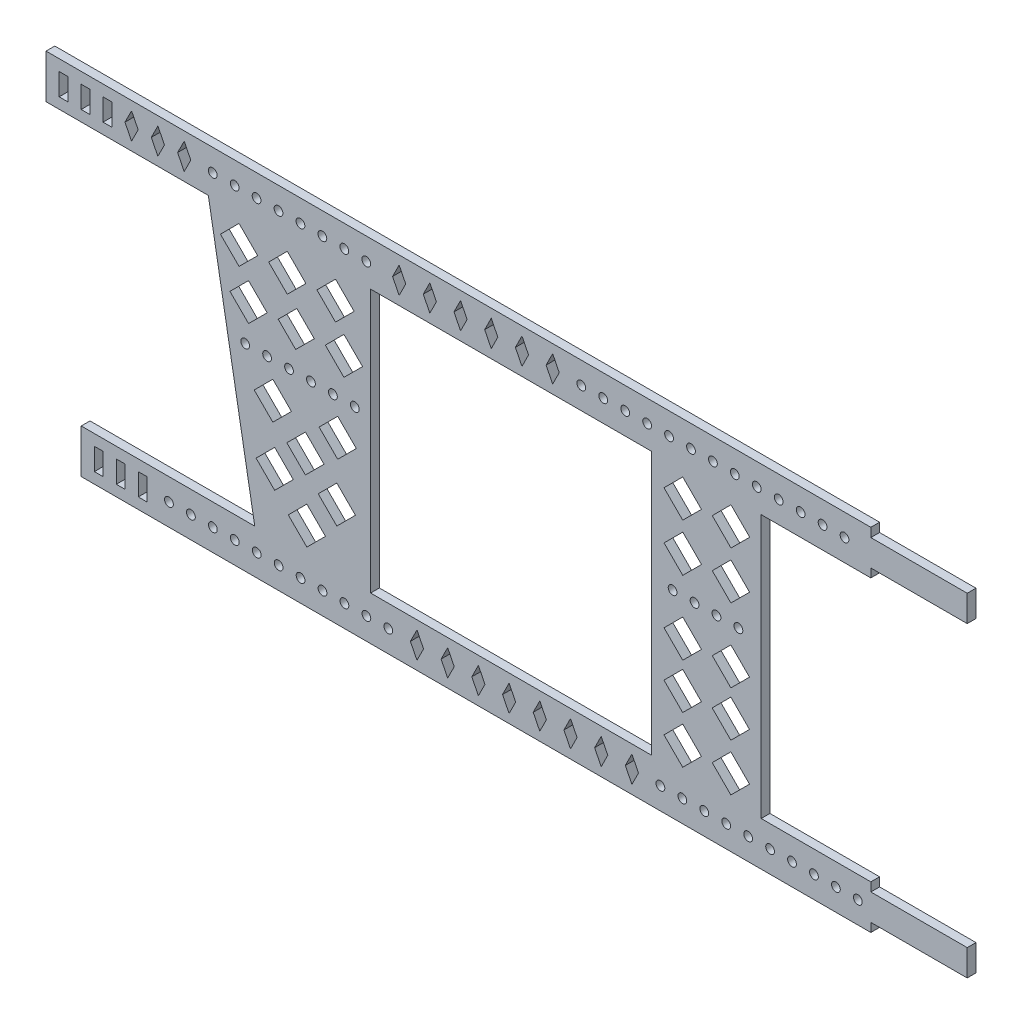
from build123d import *

# Parameters (mm, degrees)
SKETCH_1_W      = 2
SKETCH_1_H      = 5
SKETCH_1_R      = 1
SKETCH_1_W_2    = 64.030489503
SKETCH_1_H_2    = 60
EXTRUDE_1_DEPTH = 2


with BuildPart() as part:
    # 草图1 → 凸台-拉伸1 (new body)
    with BuildSketch(Plane.XY):
        Polygon((88.030596148, 5.035282886), (-99.999893355, 5.035282886), (-99.999893355, -4.964717114), (-62.999893355, -4.964717114), (-52.420274512, -64.964717114), (-91.969403852, -64.964717114), (-91.969403852, -74.964717114), (88.030596148, -74.964717114), (88.030596148, -72.964717114), (110.000106645, -72.964717114), (110.000106645, -66.964717114), (88.030596148, -66.964717114), (88.030596148, -64.964717114), (63.030596148, -64.964717114), (63.030596148, -4.964717114), (88.030596148, -4.964717114), (88.030596148, -2.99999245), (110.000106645, -2.99999245), (110.000106645, 3.00000755), (88.030596148, 3.00000755), align=None)
        with Locations((-87.969403852, -69.977475528)):
            Rectangle(SKETCH_1_W, SKETCH_1_H, mode=Mode.SUBTRACT)
        with Locations((-82.969403852, -69.977475528)):
            Rectangle(SKETCH_1_W, SKETCH_1_H, mode=Mode.SUBTRACT)
        with Locations((-77.969403852, -69.977475528)):
            Rectangle(SKETCH_1_W, SKETCH_1_H, mode=Mode.SUBTRACT)
        with Locations((-71.969403852, -69.964717114)):
            Circle(SKETCH_1_R, mode=Mode.SUBTRACT)
        with Locations((-66.969403852, -69.964717114)):
            Circle(SKETCH_1_R, mode=Mode.SUBTRACT)
        with Locations((-61.969403852, -69.964717114)):
            Circle(SKETCH_1_R, mode=Mode.SUBTRACT)
        with Locations((-56.969403852, -69.964717114)):
            Circle(SKETCH_1_R, mode=Mode.SUBTRACT)
        with Locations((-51.969403852, -69.964717114)):
            Circle(SKETCH_1_R, mode=Mode.SUBTRACT)
        with Locations((-46.969403852, -69.964717114)):
            Circle(SKETCH_1_R, mode=Mode.SUBTRACT)
        with Locations((-41.969403852, -69.964717114)):
            Circle(SKETCH_1_R, mode=Mode.SUBTRACT)
        with Locations((-36.969403852, -69.964717114)):
            Circle(SKETCH_1_R, mode=Mode.SUBTRACT)
        with Locations((-31.969403852, -69.964717114)):
            Circle(SKETCH_1_R, mode=Mode.SUBTRACT)
        with Locations((-26.969403852, -69.964717114)):
            Circle(SKETCH_1_R, mode=Mode.SUBTRACT)
        with Locations((-21.969403852, -69.964717114)):
            Circle(SKETCH_1_R, mode=Mode.SUBTRACT)
        Polygon((-15.435372884, -66.966180231), (-13.935372884, -69.966187781), (-15.435372884, -72.966195331), (-16.935372884, -69.966187781), align=None, mode=Mode.SUBTRACT)
        Polygon((-8.435372884, -72.966195331), (-9.935372884, -69.966187781), (-8.435372884, -66.966180231), (-6.935372884, -69.966187781), align=None, mode=Mode.SUBTRACT)
        Polygon((-44.780702844, -58.918058275), (-40.538062157, -54.675417588), (-36.29542147, -58.918058275), (-40.538062157, -63.160698962), align=None, mode=Mode.SUBTRACT)
        Polygon((-52.114588356, -51.383697663), (-47.871947669, -47.141056976), (-43.629306982, -51.383697663), (-47.871947669, -55.62633835), align=None, mode=Mode.SUBTRACT)
        Polygon((-37.95128426, -51.345378073), (-33.708643573, -47.102737386), (-29.466002886, -51.345378073), (-33.708643573, -55.58801876), align=None, mode=Mode.SUBTRACT)
        Polygon((-45.106332508, -44.847494945), (-40.863691821, -40.604854258), (-36.621051134, -44.847494945), (-40.863691821, -49.090135632), align=None, mode=Mode.SUBTRACT)
        Polygon((-52.536676588, -38.141926095), (-48.294035901, -33.899285408), (-44.051395214, -38.141926095), (-48.294035901, -42.384566782), align=None, mode=Mode.SUBTRACT)
        Polygon((-37.748086888, -38.065793199), (-33.505446201, -33.823152512), (-29.262805514, -38.065793199), (-33.505446201, -42.308433886), align=None, mode=Mode.SUBTRACT)
        Polygon((-1.435372884, -72.966195331), (-2.935372884, -69.966187781), (-1.435372884, -66.966180231), (0.064627116, -69.966187781), align=None, mode=Mode.SUBTRACT)
        Polygon((5.564627116, -72.966195331), (4.064627116, -69.966187781), (5.564627116, -66.966180231), (7.064627116, -69.966187781), align=None, mode=Mode.SUBTRACT)
        Polygon((12.564627116, -72.966195331), (11.064627116, -69.966187781), (12.564627116, -66.966180231), (14.064627116, -69.966187781), align=None, mode=Mode.SUBTRACT)
        Polygon((19.564627116, -72.966195331), (18.064627116, -69.966187781), (19.564627116, -66.966180231), (21.064627116, -69.966187781), align=None, mode=Mode.SUBTRACT)
        Polygon((26.564627116, -72.966195331), (25.064627116, -69.966187781), (26.564627116, -66.966180231), (28.064627116, -69.966187781), align=None, mode=Mode.SUBTRACT)
        Polygon((33.564627116, -72.966195331), (32.064627116, -69.966187781), (33.564627116, -66.966180231), (35.064627116, -69.966187781), align=None, mode=Mode.SUBTRACT)
        with Locations((40.064627116, -69.964717114)):
            Circle(SKETCH_1_R, mode=Mode.SUBTRACT)
        with Locations((45.064627116, -69.964717114)):
            Circle(SKETCH_1_R, mode=Mode.SUBTRACT)
        with Locations((50.064627116, -69.964717114)):
            Circle(SKETCH_1_R, mode=Mode.SUBTRACT)
        with Locations((55.064627116, -69.964717114)):
            Circle(SKETCH_1_R, mode=Mode.SUBTRACT)
        with Locations((60.064627116, -69.964717114)):
            Circle(SKETCH_1_R, mode=Mode.SUBTRACT)
        with Locations((65.064627116, -69.964717114)):
            Circle(SKETCH_1_R, mode=Mode.SUBTRACT)
        with Locations((70.064627116, -69.964717114)):
            Circle(SKETCH_1_R, mode=Mode.SUBTRACT)
        with Locations((75.064627116, -69.964717114)):
            Circle(SKETCH_1_R, mode=Mode.SUBTRACT)
        with Locations((80.064627116, -69.964717114)):
            Circle(SKETCH_1_R, mode=Mode.SUBTRACT)
        with Locations((85.064627116, -69.964717114)):
            Circle(SKETCH_1_R, mode=Mode.SUBTRACT)
        Polygon((40.877840935, -59.522953409), (45.145983497, -55.254810846), (49.41412606, -59.522953409), (45.145983497, -63.791095971), align=None, mode=Mode.SUBTRACT)
        Polygon((51.865089997, -59.510202471), (56.120481622, -55.254810846), (60.375873246, -59.510202471), (56.120481622, -63.765594096), align=None, mode=Mode.SUBTRACT)
        with Locations((6.015351396, -34.964717114)):
            Rectangle(SKETCH_1_W_2, SKETCH_1_H_2, mode=Mode.SUBTRACT)
        Polygon((40.87382717, -48.72025407), (45.141969733, -44.452111507), (49.410112295, -48.72025407), (45.141969733, -52.988396632), align=None, mode=Mode.SUBTRACT)
        Polygon((51.861076232, -48.707503132), (56.116467857, -44.452111507), (60.371859482, -48.707503132), (56.116467857, -52.962894757), align=None, mode=Mode.SUBTRACT)
        Polygon((40.887199733, -38.383165413), (45.155342296, -34.115022851), (49.423484858, -38.383165413), (45.155342296, -42.651307976), align=None, mode=Mode.SUBTRACT)
        Polygon((51.887199733, -38.383165413), (56.12984042, -34.140524726), (60.372481107, -38.383165413), (56.12984042, -42.6258061), align=None, mode=Mode.SUBTRACT)
        with Locations((-54.598317058, -29.99999245)):
            Circle(SKETCH_1_R, mode=Mode.SUBTRACT)
        Polygon((-58.070528094, -21.436133175), (-53.827887407, -17.193492488), (-49.58524672, -21.436133175), (-53.827887407, -25.678773862), align=None, mode=Mode.SUBTRACT)
        with Locations((-49.598317058, -29.99999245)):
            Circle(SKETCH_1_R, mode=Mode.SUBTRACT)
        with Locations((-44.598317058, -29.99999245)):
            Circle(SKETCH_1_R, mode=Mode.SUBTRACT)
        with Locations((-39.598317058, -29.99999245)):
            Circle(SKETCH_1_R, mode=Mode.SUBTRACT)
        with Locations((-34.598317058, -29.99999245)):
            Circle(SKETCH_1_R, mode=Mode.SUBTRACT)
        with Locations((-29.598317058, -29.99999245)):
            Circle(SKETCH_1_R, mode=Mode.SUBTRACT)
        Polygon((-47.070528094, -21.436133175), (-42.827887407, -17.193492488), (-38.839924125, -21.18145577), (-43.082564812, -25.424096457), align=None, mode=Mode.SUBTRACT)
        Polygon((-36.325205499, -21.18145577), (-32.082564812, -16.938815083), (-27.839924125, -21.18145577), (-32.082564812, -25.424096457), align=None, mode=Mode.SUBTRACT)
        Polygon((-60.241215598, -11.234867157), (-55.998574911, -6.99222647), (-51.755934224, -11.234867157), (-55.998574911, -15.477507844), align=None, mode=Mode.SUBTRACT)
        with Locations((-96.000048897, 8.067e-06)):
            Rectangle(SKETCH_1_W, SKETCH_1_H, mode=Mode.SUBTRACT)
        with Locations((-91.000048897, 8.067e-06)):
            Rectangle(SKETCH_1_W, SKETCH_1_H, mode=Mode.SUBTRACT)
        with Locations((-86.000048897, 8.067e-06)):
            Rectangle(SKETCH_1_W, SKETCH_1_H, mode=Mode.SUBTRACT)
        Polygon((-80.499946677, -3.000106646), (-82.000048897, 0.000105344), (-80.499995574, 3.00021954), (-78.999893355, 7.55e-06), align=None, mode=Mode.SUBTRACT)
        Polygon((-74.499946677, -3.000106646), (-76.000048897, 0.000105344), (-74.499995574, 3.00021954), (-72.999893355, 7.55e-06), align=None, mode=Mode.SUBTRACT)
        Polygon((-68.499946677, -3.000106646), (-70.000048897, 0.000105344), (-68.499995574, 3.00021954), (-66.999893355, 7.55e-06), align=None, mode=Mode.SUBTRACT)
        with Locations((-61.999893355, 7.55e-06)):
            Circle(SKETCH_1_R, mode=Mode.SUBTRACT)
        with Locations((-56.999893355, 7.55e-06)):
            Circle(SKETCH_1_R, mode=Mode.SUBTRACT)
        with Locations((-51.999893355, 7.55e-06)):
            Circle(SKETCH_1_R, mode=Mode.SUBTRACT)
        Polygon((-49.241215598, -11.234867157), (-44.998574911, -6.99222647), (-40.755934224, -11.234867157), (-44.998574911, -15.477507844), align=None, mode=Mode.SUBTRACT)
        Polygon((-33.998574911, -6.99222647), (-29.755934224, -11.234867157), (-33.998574911, -15.477507844), (-38.241215598, -11.234867157), align=None, mode=Mode.SUBTRACT)
        with Locations((-46.999893355, 7.55e-06)):
            Circle(SKETCH_1_R, mode=Mode.SUBTRACT)
        with Locations((-41.999893355, 7.55e-06)):
            Circle(SKETCH_1_R, mode=Mode.SUBTRACT)
        with Locations((-36.999893355, 7.55e-06)):
            Circle(SKETCH_1_R, mode=Mode.SUBTRACT)
        with Locations((-31.999893355, 7.55e-06)):
            Circle(SKETCH_1_R, mode=Mode.SUBTRACT)
        with Locations((-26.999893355, 7.55e-06)):
            Circle(SKETCH_1_R, mode=Mode.SUBTRACT)
        Polygon((-19.499994314, -2.960033292), (-20.999994314, 0.039974259), (-19.499994314, 3.039981809), (-17.999994314, 0.039974259), align=None, mode=Mode.SUBTRACT)
        Polygon((-12.499994314, -2.960033292), (-13.999994314, 0.039974259), (-12.499994314, 3.039981809), (-10.999994314, 0.039974259), align=None, mode=Mode.SUBTRACT)
        Polygon((-5.499994314, -2.960033292), (-6.999994314, 0.039974259), (-5.499994314, 3.039981809), (-3.999994314, 0.039974259), align=None, mode=Mode.SUBTRACT)
        with Locations((42.844614024, -29.964205592)):
            Circle(SKETCH_1_R, mode=Mode.SUBTRACT)
        with Locations((47.844614024, -29.964205592)):
            Circle(SKETCH_1_R, mode=Mode.SUBTRACT)
        with Locations((52.844614024, -29.964205592)):
            Circle(SKETCH_1_R, mode=Mode.SUBTRACT)
        with Locations((57.844614024, -29.964205592)):
            Circle(SKETCH_1_R, mode=Mode.SUBTRACT)
        Polygon((40.888975631, -21.619966166), (45.157118193, -17.351823604), (49.425260756, -21.619966166), (45.157118193, -25.888108729), align=None, mode=Mode.SUBTRACT)
        Polygon((51.876224693, -21.607215228), (56.131616318, -17.351823604), (60.387007942, -21.607215228), (56.131616318, -25.862606853), align=None, mode=Mode.SUBTRACT)
        Polygon((1.500005686, -2.960033292), (5.686e-06, 0.039974259), (1.500005686, 3.039981809), (3.000005686, 0.039974259), align=None, mode=Mode.SUBTRACT)
        Polygon((8.500005686, -2.960033292), (7.000005686, 0.039974259), (8.500005686, 3.039981809), (10.000005686, 0.039974259), align=None, mode=Mode.SUBTRACT)
        Polygon((15.500005686, -2.960033292), (14.000005686, 0.039974259), (15.500005686, 3.039981809), (17.000005686, 0.039974259), align=None, mode=Mode.SUBTRACT)
        with Locations((22.030596148, 0.033051711)):
            Circle(SKETCH_1_R, mode=Mode.SUBTRACT)
        with Locations((27.030596148, 0.033051711)):
            Circle(SKETCH_1_R, mode=Mode.SUBTRACT)
        with Locations((32.030596148, 0.033051711)):
            Circle(SKETCH_1_R, mode=Mode.SUBTRACT)
        with Locations((37.030596148, 0.033051711)):
            Circle(SKETCH_1_R, mode=Mode.SUBTRACT)
        Polygon((40.881123238, -10.736981843), (45.149265801, -6.46883928), (49.417408363, -10.736981843), (45.149265801, -15.005124406), align=None, mode=Mode.SUBTRACT)
        Polygon((56.149265801, -6.46883928), (60.417408363, -10.736981843), (56.149265801, -15.005124406), (51.881123238, -10.736981843), align=None, mode=Mode.SUBTRACT)
        with Locations((42.030596148, 0.033051711)):
            Circle(SKETCH_1_R, mode=Mode.SUBTRACT)
        with Locations((47.030596148, 0.033051711)):
            Circle(SKETCH_1_R, mode=Mode.SUBTRACT)
        with Locations((52.030596148, 0.033051711)):
            Circle(SKETCH_1_R, mode=Mode.SUBTRACT)
        with Locations((57.030596148, 0.033051711)):
            Circle(SKETCH_1_R, mode=Mode.SUBTRACT)
        with Locations((62.030596148, 0.033051711)):
            Circle(SKETCH_1_R, mode=Mode.SUBTRACT)
        with Locations((67.030596148, 0.033051711)):
            Circle(SKETCH_1_R, mode=Mode.SUBTRACT)
        with Locations((72.030596148, 0.033051711)):
            Circle(SKETCH_1_R, mode=Mode.SUBTRACT)
        with Locations((77.030596148, 0.033051711)):
            Circle(SKETCH_1_R, mode=Mode.SUBTRACT)
        with Locations((82.030596148, 0.033051711)):
            Circle(SKETCH_1_R, mode=Mode.SUBTRACT)
    extrude(amount=EXTRUDE_1_DEPTH)


solid = part.part
